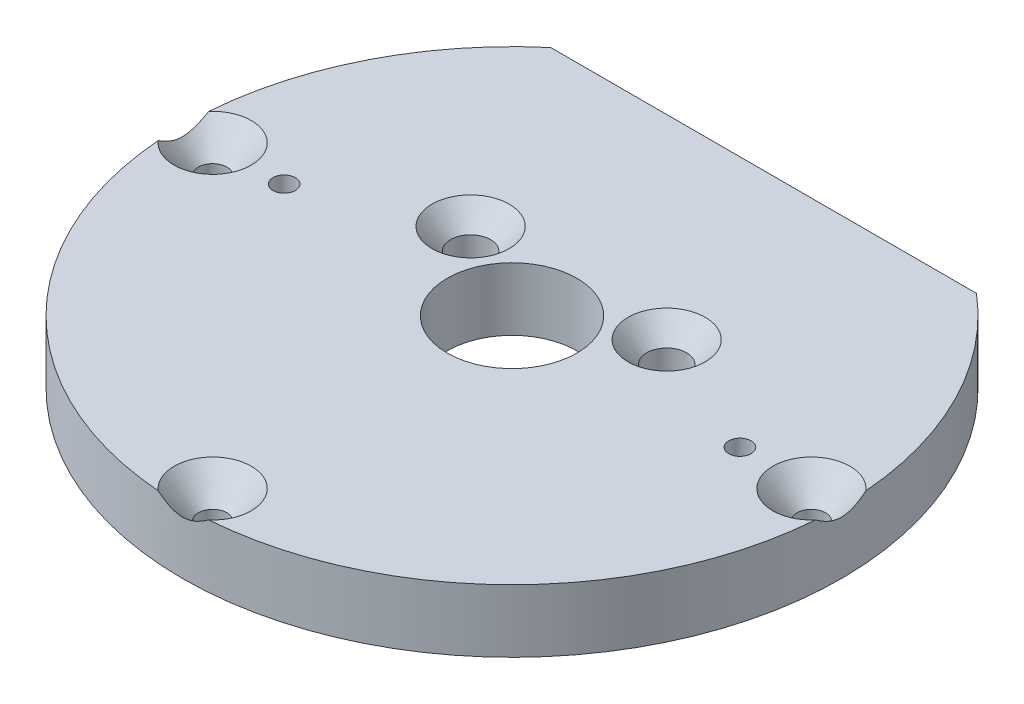
from build123d import *

# Parameters (mm, degrees)
SKETCH1_R                    = 33.274
BOSS_EXTRUDE1_DEPTH          = 6.35
PLATEMTGSCREW_D              = 2.8702
PLATEMTGSCREW_DEPTH          = 10.1854
PLATEMTGSCREW_CSINK_D        = 7.7978
PLATEMTGSCREW_CSINK_ANGLE    = 82
PLATEMTGSCREW_TIP            = 0.862295074
ENCODERMTGHOLES_D            = 2.2606
SLIPRGSHFTCLR_D              = 13.09624
SLIPRGSHFTCLR_DEPTH          = 6.35
SLIPRGSHFTCLR_TIP            = 3.934507437
ADDITIONAL_HOLES_D           = 4.0386
ADDITIONAL_HOLES_CSINK_D     = 7.7978
ADDITIONAL_HOLES_CSINK_ANGLE = 82
CUT_EXTRUDE1_DEPTH           = 7.3500001


with BuildPart() as part:
    # Sketch1 → Boss-Extrude1 (new body)
    with BuildSketch(Plane(origin=(0, 0, 0), x_dir=(1, 0, 0), z_dir=(0, 1, 0))):
        Circle(SKETCH1_R)
    extrude(amount=BOSS_EXTRUDE1_DEPTH)

    # PlateMtgScrew
    with Locations(Plane(origin=(0, 6.35, 0), x_dir=(1, 0, 0), z_dir=(0, 1, 0))):
        with Locations((30.226, 0), (-30.226, 0), (0, -30.226)):
            CounterSinkHole(PLATEMTGSCREW_D / 2, PLATEMTGSCREW_CSINK_D / 2, depth=PLATEMTGSCREW_DEPTH, counter_sink_angle=PLATEMTGSCREW_CSINK_ANGLE)
            with Locations((0, 0, -(PLATEMTGSCREW_DEPTH + PLATEMTGSCREW_TIP / 2))):  # 118° drill point
                Cone(0, PLATEMTGSCREW_D / 2, PLATEMTGSCREW_TIP, mode=Mode.SUBTRACT)

    # EncoderMtgHoles (through all)
    with Locations(Plane(origin=(0, 6.35, 0), x_dir=(1, 0, 0), z_dir=(0, 1, 0))):
        with Locations((23.0124, 0), (-23.0124, 0)):
            Hole(ENCODERMTGHOLES_D / 2)

    # SlipRgShftClr
    with Locations(Plane(origin=(0, 6.35, 0), x_dir=(1, 0, 0), z_dir=(0, 1, 0))):
        with Locations((0, 0)):
            Hole(SLIPRGSHFTCLR_D / 2, depth=SLIPRGSHFTCLR_DEPTH)
            with Locations((0, 0, -(SLIPRGSHFTCLR_DEPTH + SLIPRGSHFTCLR_TIP / 2))):  # 118° drill point
                Cone(0, SLIPRGSHFTCLR_D / 2, SLIPRGSHFTCLR_TIP, mode=Mode.SUBTRACT)

    # Additional Holes (through all)
    with Locations(Plane(origin=(0, 6.35, 0), x_dir=(1, 0, 0), z_dir=(0, 1, 0))):
        with Locations((-9.898670365, 5.715), (9.898670365, 5.715)):
            CounterSinkHole(ADDITIONAL_HOLES_D / 2, ADDITIONAL_HOLES_CSINK_D / 2, counter_sink_angle=ADDITIONAL_HOLES_CSINK_ANGLE)

    # Sketch16 → Cut-Extrude1 (cut, through all)
    with BuildSketch(Plane(origin=(0, 6.35, 0), x_dir=(1, 0, 0), z_dir=(0, 1, 0))):
        Polygon((-192.02067324, 25.4), (-21.494163766, 25.4), (21.494163766, 25.4), (192.02067324, 25.4), (192.02067324, 366.453018948), (-192.02067324, 366.453018948), align=None)
    extrude(amount=-CUT_EXTRUDE1_DEPTH, mode=Mode.SUBTRACT)


solid = part.part
